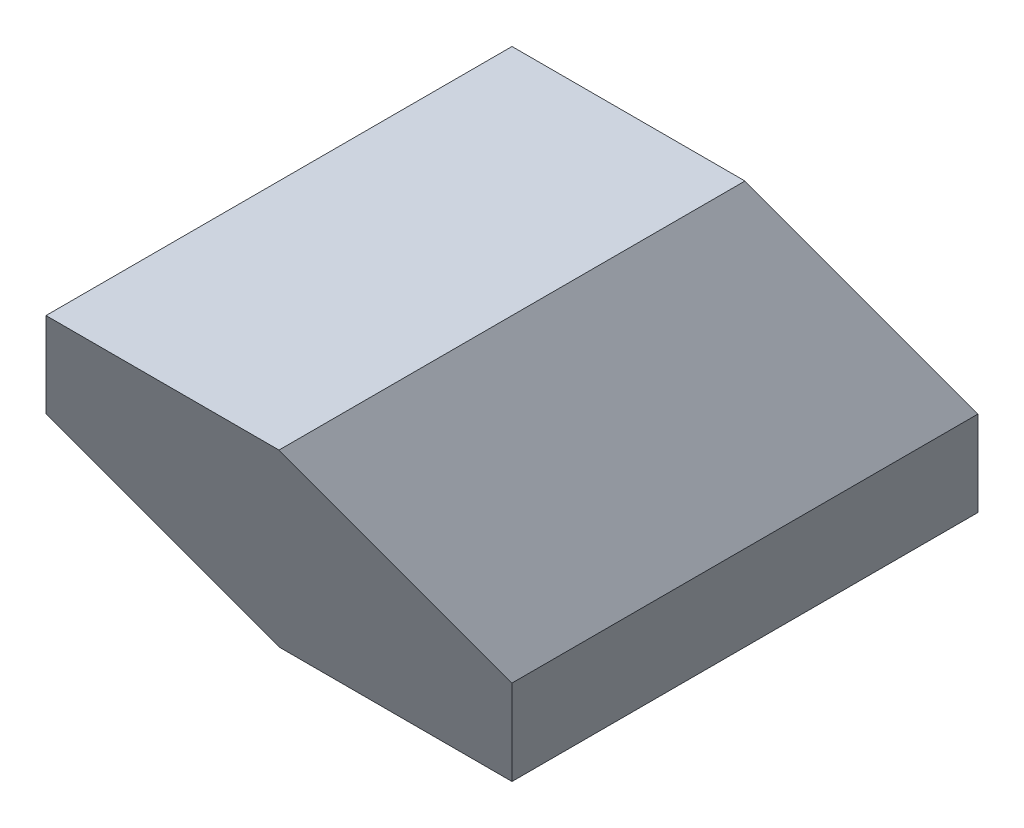
from build123d import *

# Parameters (mm, degrees)
EXTRUDE1_DEPTH     = 65
CUT_EXTRUDE1_DEPTH = 45


with BuildPart() as part:
    # Sketch1 → Extrude1 (new body, symmetric)
    with BuildSketch(Plane.XY):
        Polygon((40.414518843, 0), (20.207259422, 35), (-20.207259422, 35), (-40.414518843, 0), (-20.207259422, -35), (20.207259422, -35), align=None)
    extrude(amount=EXTRUDE1_DEPTH, both=True)

    # Sketch3 → Cut-Extrude1 (cut, symmetric)
    with BuildSketch(Plane(origin=(0, 0, 0), x_dir=(0, 0, -1), z_dir=(1, 0, 0))):
        Polygon((65, -35), (65, 35), (20.207259422, 35), (60.621778265, -35), align=None)
        Polygon((-60.621778265, 35), (-20.207259422, -35), (-65, -35), (-65, 35), align=None)
    extrude(amount=CUT_EXTRUDE1_DEPTH, both=True, mode=Mode.SUBTRACT)


with BuildPart() as body_2:
    # Sketch2 → Revolve1 (revolve)
    with BuildSketch(Plane.XY):
        with BuildLine():
            Line((0, 35), (0, -35))
            ThreePointArc((0, -35), (35, 0), (0, 35))
        make_face()
    revolve(axis=Axis((0, 35, 0), (0, -1, 0)))


solid = Compound([part.part, body_2.part])
